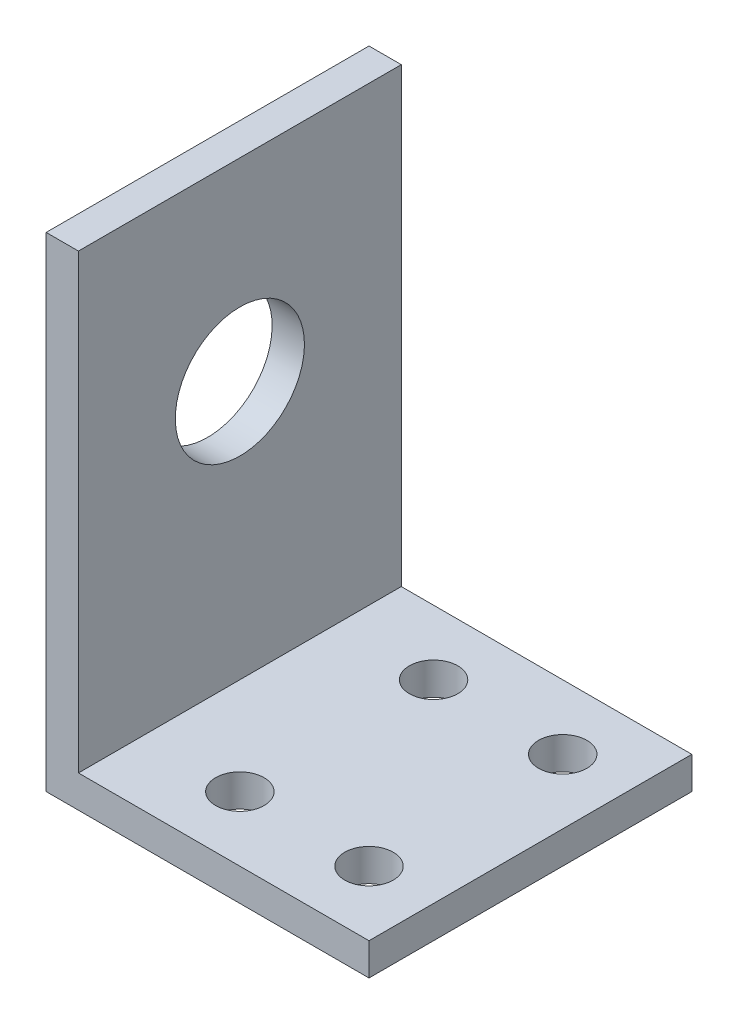
from build123d import *

# Parameters (mm, degrees)
EXTRUDE_1_DEPTH     = 20
SKETCH_2_R          = 1.5
CUT_EXTRUDE_1_DEPTH = 4
SKETCH_3_R          = 4
CUT_EXTRUDE_2_DEPTH = 4
SKETCH_4_R          = 1.5
CUT_EXTRUDE_3_DEPTH = 20
SKETCH_5_W          = 3
SKETCH_5_H          = 20
CUT_EXTRUDE_4_DEPTH = 8
SKETCH_6_W          = 20
SKETCH_6_H          = 27
CUT_EXTRUDE_5_DEPTH = 1
SKETCH_7_W          = 18
SKETCH_7_H          = 20
CUT_EXTRUDE_6_DEPTH = 1


with BuildPart() as part:
    # 草图1 → 凸台-拉伸1 (new body)
    with BuildSketch(Plane.XY):
        Polygon((0, 0), (0, 38), (3, 38), (3, 3), (20, 3), (20, 0), align=None)
    extrude(amount=EXTRUDE_1_DEPTH)

    # 草图2 → 切除-拉伸1 (cut, through all)
    with BuildSketch(Plane(origin=(0, 3, 0), x_dir=(1, 0, 0), z_dir=(0, 1, 0))):
        with Locations((16, -16)):
            Circle(SKETCH_2_R)
        with Locations((16, -4)):
            Circle(SKETCH_2_R)
    extrude(amount=-CUT_EXTRUDE_1_DEPTH, mode=Mode.SUBTRACT)

    # 草图3 → 切除-拉伸2 (cut, through all)
    with BuildSketch(Plane(origin=(3, 0, 0), x_dir=(0, 0, -1), z_dir=(1, 0, 0))):
        with Locations((-10, 18)):
            Circle(SKETCH_3_R)
    extrude(amount=-CUT_EXTRUDE_2_DEPTH, mode=Mode.SUBTRACT)

    # 草图4 → 切除-拉伸3 (cut)
    with BuildSketch(Plane(origin=(0, 3, 0), x_dir=(1, 0, 0), z_dir=(0, 1, 0))):
        with Locations((8, -16)):
            Circle(SKETCH_4_R)
        with Locations((8, -4)):
            Circle(SKETCH_4_R)
    extrude(amount=-CUT_EXTRUDE_3_DEPTH, mode=Mode.SUBTRACT)

    # 草图5 → 切除-拉伸4 (cut)
    with BuildSketch(Plane(origin=(0, 38, 0), x_dir=(1, 0, 0), z_dir=(0, 1, 0))):
        with Locations((1.5, -10)):
            Rectangle(SKETCH_5_W, SKETCH_5_H)
    extrude(amount=-CUT_EXTRUDE_4_DEPTH, mode=Mode.SUBTRACT)

    # 草图6 → 切除-拉伸5 (cut)
    with BuildSketch(Plane(origin=(3, 0, 0), x_dir=(0, 0, -1), z_dir=(1, 0, 0))):
        with Locations((-10, 16.5)):
            Rectangle(SKETCH_6_W, SKETCH_6_H)
    extrude(amount=-CUT_EXTRUDE_5_DEPTH, mode=Mode.SUBTRACT)

    # 草图7 → 切除-拉伸6 (cut)
    with BuildSketch(Plane(origin=(0, 3, 0), x_dir=(1, 0, 0), z_dir=(0, 1, 0))):
        with Locations((11, -10)):
            Rectangle(SKETCH_7_W, SKETCH_7_H)
    extrude(amount=-CUT_EXTRUDE_6_DEPTH, mode=Mode.SUBTRACT)


solid = part.part
